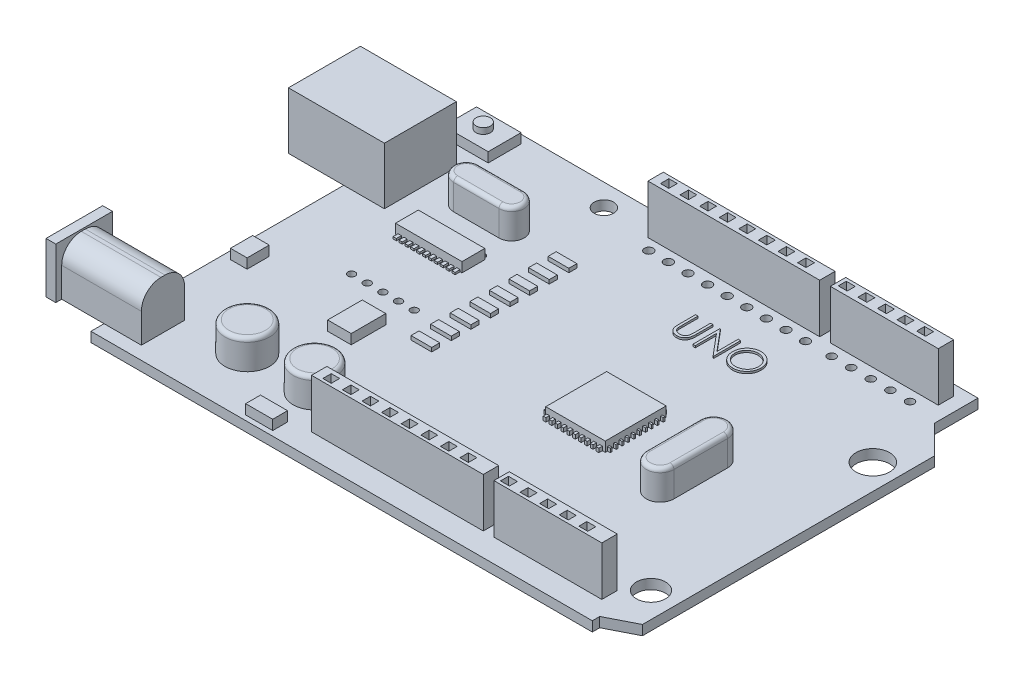
from build123d import *

# Parameters (mm, degrees)
BOSS_EXTRUDE1_DEPTH  = 1.27
SKETCH3_W            = 12.439804233
SKETCH3_H            = 9.329853175
BOSS_EXTRUDE2_DEPTH  = 7.366
SKETCH4_W            = 7.322225457
SKETCH4_H            = 5.447021376
CUT_EXTRUDE1_DEPTH   = 7.366
SKETCH5_W            = 5.784834909
SKETCH5_H            = 4.274350239
BOSS_EXTRUDE3_DEPTH  = 1.27
SKETCH6_R            = 0.927751565
BOSS_EXTRUDE4_DEPTH  = 0.762
SKETCH7_W            = 11.59930364
SKETCH7_H            = 5.603053453
BOSS_EXTRUDE5_DEPTH  = 6.35
FILLET1_R            = 2.54
SKETCH8_W            = 7.353569952
SKETCH8_H            = 6.576337341
BOSS_EXTRUDE6_DEPTH  = 1.27
SKETCH9_R            = 1.784291515
CUT_EXTRUDE2_DEPTH   = 8.89
SKETCH10_W           = 3.393226432
SKETCH10_H           = 2.053794946
BOSS_EXTRUDE7_DEPTH  = 6.35
SKETCH11_R           = 2.891497506
SKETCH11_R_2         = 2.784780473
BOSS_EXTRUDE8_DEPTH  = 3.81
FILLET2_R            = 0.508
FILLET3_R            = 0.508
SKETCH12_W           = 22.265357201
SKETCH12_H           = 1.994930287
SKETCH12_W_2         = 13.992855705
BOSS_EXTRUDE9_DEPTH  = 6.35
SKETCH13_W           = 1.092691039
SKETCH13_H           = 1.092691039
CUT_EXTRUDE3_DEPTH   = 3.81
SKETCH14_W           = 1.159162775
SKETCH14_H           = 1.037145641
CUT_EXTRUDE4_DEPTH   = 3.81
SKETCH15_W           = 7.718255282
SKETCH15_H           = 7.897749591
SKETCH15_W_2         = 8.615726825
SKETCH15_H_2         = 2.961656096
SKETCH15_W_3         = 3.051403251
SKETCH15_H_3         = 4.487357722
SKETCH15_W_4         = 2.153931706
SKETCH15_H_4         = 2.871908942
SKETCH15_W_5         = 3.504585901
SKETCH15_H_5         = 1.927522246
BOSS_EXTRUDE10_DEPTH = 1.27
SKETCH16_R           = 1.256460162
SKETCH16_R_2         = 2.179521727
SKETCH16_R_3         = 1.893030276
SKETCH16_R_4         = 0.477788407
CUT_EXTRUDE5_DEPTH   = 3.81
SKETCH17_W           = 2.681644975
SKETCH17_H           = 1.042861934
BOSS_EXTRUDE11_DEPTH = 0.508
SKETCH20_R           = 0.567610843
CUT_EXTRUDE6_DEPTH   = 23.368
SKETCH21_R           = 0.528248536
CUT_EXTRUDE7_DEPTH   = 13.208
SKETCH22_W           = 0.352103618
SKETCH22_H           = 0.914597611
BOSS_EXTRUDE12_DEPTH = 0.508
SKETCH24_W           = 0.515246595
SKETCH24_H           = 0.230378191
SKETCH24_W_2         = 0.272737657
SKETCH24_H_2         = 0.764205128
BOSS_EXTRUDE13_DEPTH = 0.508
BOSS_EXTRUDE14_DEPTH = 0.254
SKETCH25_W           = 0.425674813
SKETCH25_H           = 4.043342787
BOSS_EXTRUDE15_DEPTH = 0.254


with BuildPart() as part:
    # Sketch2 → Boss-Extrude1 (new body)
    with BuildSketch(Plane(origin=(0, 0, 0), x_dir=(1, 0, 0), z_dir=(0, 1, 0))):
        Polygon((-29.280660377, 14.027122642), (35.719339623, 14.027122642), (35.719339623, 8.393751804), (39.388318456, 4.724772971), (39.388318456, -33.137759083), (35.719339623, -35.010532784), (35.719339623, -35.972877358), (-29.280660377, -35.972877358), align=None)
    extrude(amount=BOSS_EXTRUDE1_DEPTH)

    # Sketch3 → Boss-Extrude2 (add)
    with BuildSketch(Plane(origin=(0, 1.27, 0), x_dir=(1, 0, 0), z_dir=(0, 1, 0))):
        with Locations((-30.228029518, 1.466926875)):
            Rectangle(SKETCH3_W, SKETCH3_H)
    extrude(amount=BOSS_EXTRUDE2_DEPTH)

    # Sketch4 → Cut-Extrude1 (cut)
    with BuildSketch(Plane.ZY.offset(36.447931634)):
        with Locations((-1.74420655, 5.247347114)):
            Rectangle(SKETCH4_W, SKETCH4_H)
    extrude(amount=-CUT_EXTRUDE1_DEPTH, mode=Mode.SUBTRACT)

    # Sketch5 → Boss-Extrude3 (add)
    with BuildSketch(Plane(origin=(0, 1.27, 0), x_dir=(1, 0, 0), z_dir=(0, 1, 0))):
        with Locations((-25.318252468, 10.807240534)):
            Rectangle(SKETCH5_W, SKETCH5_H)
    extrude(amount=BOSS_EXTRUDE3_DEPTH)

    # Sketch6 → Boss-Extrude4 (add)
    with BuildSketch(Plane(origin=(0, 2.54, 0), x_dir=(1, 0, 0), z_dir=(0, 1, 0))):
        with Locations((-25.328780415, 10.938907683)):
            Circle(SKETCH6_R)
    extrude(amount=BOSS_EXTRUDE4_DEPTH)

    # Sketch7 → Boss-Extrude5 (add)
    with BuildSketch(Plane(origin=(0, 1.27, 0), x_dir=(1, 0, 0), z_dir=(0, 1, 0))):
        with Locations((-30.241537665, -31.469115733)):
            Rectangle(SKETCH7_W, SKETCH7_H)
    extrude(amount=BOSS_EXTRUDE5_DEPTH)

    # Fillet1
    fillet1_edges = [part.edges().sort_by_distance(p)[0] for p in [
        (-30.241537665, 7.62, 28.667589006),
        (-30.241537665, 7.62, 34.270642459),
    ]]
    fillet(fillet1_edges, radius=FILLET1_R)

    # Sketch8 → Boss-Extrude6 (add)
    with BuildSketch(Plane.ZY.offset(36.041189485)):
        with Locations((31.359750649, 4.558168671)):
            Rectangle(SKETCH8_W, SKETCH8_H)
    extrude(amount=-BOSS_EXTRUDE6_DEPTH)

    # Sketch9 → Cut-Extrude2 (cut)
    with BuildSketch(Plane.ZY.offset(36.041189485)):
        with Locations((31.327658321, 4.299523558)):
            Circle(SKETCH9_R)
    extrude(amount=-CUT_EXTRUDE2_DEPTH, mode=Mode.SUBTRACT)

    # Sketch10 → Boss-Extrude7 (add)
    with BuildSketch(Plane.ZY.offset(29.081931634)):
        with Locations((-1.804087209, 5.063026243)):
            Rectangle(SKETCH10_W, SKETCH10_H)
    extrude(amount=BOSS_EXTRUDE7_DEPTH)

    # Sketch11 → Boss-Extrude8 (add)
    with BuildSketch(Plane(origin=(0, 1.27, 0), x_dir=(1, 0, 0), z_dir=(0, 1, 0))):
        with Locations((-16.643548114, -28.341824032)):
            Circle(SKETCH11_R)
        with Locations((-7.913597637, -28.341824032)):
            Circle(SKETCH11_R_2)
        with BuildLine():
            Line((-19.172786102, 4.211916531), (-13.298426903, 4.211916531))
            ThreePointArc((-13.298426903, 4.211916531), (-11.666660459, 2.580150087), (-13.298426903, 0.948383643))
            Line((-13.298426903, 0.948383643), (-19.172786102, 0.948383643))
            ThreePointArc((-19.172786102, 0.948383643), (-20.804552547, 2.580150087), (-19.172786102, 4.211916531))
        make_face()
        with BuildLine():
            Line((23.742671381, -17.001047244), (23.742671381, -10.066039856))
            ThreePointArc((23.742671381, -10.066039856), (25.53761447, -8.271096767), (27.332557558, -10.066039856))
            Line((27.332557558, -10.066039856), (27.332557558, -17.001047244))
            ThreePointArc((27.332557558, -17.001047244), (25.53761447, -18.795990333), (23.742671381, -17.001047244))
        make_face()
    extrude(amount=BOSS_EXTRUDE8_DEPTH)

    # Fillet2
    fillet2_edges = [part.edges().sort_by_distance(p)[0] for p in [
        (-19.53504562, 5.08, 28.341824032),
    ]]
    fillet(fillet2_edges, radius=FILLET2_R)

    # Fillet3
    fillet3_edges = [part.edges().sort_by_distance(p)[0] for p in [
        (-10.69837811, 5.08, 28.341824032),
        (-20.804552547, 5.08, -2.580150087),
        (-16.235606503, 5.08, -0.948383643),
        (-11.666660459, 5.08, -2.580150087),
        (-16.235606503, 5.08, -4.211916531),
        (25.53761447, 5.08, 18.795990333),
        (27.332557558, 5.08, 13.53354355),
        (25.53761447, 5.08, 8.271096767),
        (23.742671381, 5.08, 13.53354355),
    ]]
    fillet(fillet3_edges, radius=FILLET3_R)

    # Sketch12 → Boss-Extrude9 (add)
    with BuildSketch(Plane(origin=(0, 1.27, 0), x_dir=(1, 0, 0), z_dir=(0, 1, 0))):
        with Locations((7.441922192, 11.648436516)):
            Rectangle(SKETCH12_W, SKETCH12_H)
        with Locations((26.947539044, 11.648436516)):
            Rectangle(SKETCH12_W_2, SKETCH12_H)
    boss_extrude9 = extrude(amount=BOSS_EXTRUDE9_DEPTH)

    # Sketch13 → Cut-Extrude3 (cut)
    with BuildSketch(Plane(origin=(0, 7.62, 0), x_dir=(1, 0, 0), z_dir=(0, 1, 0))):
        with Locations((0.486116413, 11.725008127)):
            Rectangle(SKETCH13_W, SKETCH13_H)
        with Locations((-2.053883588, 11.725008127)):
            Rectangle(SKETCH13_W, SKETCH13_H)
        with Locations((3.026116413, 11.725008127)):
            Rectangle(SKETCH13_W, SKETCH13_H)
        with Locations((5.566116413, 11.725008127)):
            Rectangle(SKETCH13_W, SKETCH13_H)
        with Locations((8.106116413, 11.725008127)):
            Rectangle(SKETCH13_W, SKETCH13_H)
        with Locations((10.646116412, 11.725008127)):
            Rectangle(SKETCH13_W, SKETCH13_H)
        with Locations((13.186116413, 11.725008127)):
            Rectangle(SKETCH13_W, SKETCH13_H)
        with Locations((15.726116413, 11.725008127)):
            Rectangle(SKETCH13_W, SKETCH13_H)
    cut_extrude3 = extrude(amount=-CUT_EXTRUDE3_DEPTH, mode=Mode.SUBTRACT)

    # Sketch14 → Cut-Extrude4 (cut)
    with BuildSketch(Plane(origin=(0, 7.62, 0), x_dir=(1, 0, 0), z_dir=(0, 1, 0))):
        with Locations((20.994355557, 11.737127992)):
            Rectangle(SKETCH14_W, SKETCH14_H)
        with Locations((23.534355557, 11.737127992)):
            Rectangle(SKETCH14_W, SKETCH14_H)
        with Locations((26.074355557, 11.737127992)):
            Rectangle(SKETCH14_W, SKETCH14_H)
        with Locations((28.614355557, 11.737127992)):
            Rectangle(SKETCH14_W, SKETCH14_H)
        with Locations((31.154355557, 11.737127992)):
            Rectangle(SKETCH14_W, SKETCH14_H)
    cut_extrude4 = extrude(amount=-CUT_EXTRUDE4_DEPTH, mode=Mode.SUBTRACT)

    # Mirror1: Boss-Extrude9, Cut-Extrude3 across Plane1
    add(boss_extrude9.mirror(Plane.XY.offset(10.16)))
    add(cut_extrude3.mirror(Plane.XY.offset(10.16)), mode=Mode.SUBTRACT)

    # Mirror2: Cut-Extrude4 across plane
    add(cut_extrude4.mirror(Plane.XY.offset(10.16)), mode=Mode.SUBTRACT)

    # Sketch15 → Boss-Extrude10 (add)
    with BuildSketch(Plane(origin=(0, 1.27, 0), x_dir=(1, 0, 0), z_dir=(0, 1, 0))):
        with Locations((13.795002464, -12.281332963)):
            Rectangle(SKETCH15_W, SKETCH15_H)
        with Locations((-16.090799963, -3.889974023)):
            Rectangle(SKETCH15_W_2, SKETCH15_H_2)
        with Locations((-12.411166631, -18.384139464)):
            Rectangle(SKETCH15_W_3, SKETCH15_H_3)
        with Locations((-27.206493385, -17.445373353)):
            Rectangle(SKETCH15_W_4, SKETCH15_H_4)
        with Locations((-8.102029847, -34.375255486)):
            Rectangle(SKETCH15_W_5, SKETCH15_H_5)
    extrude(amount=BOSS_EXTRUDE10_DEPTH)

    # Sketch16 → Cut-Extrude5 (cut)
    with BuildSketch(Plane(origin=(0, 1.27, 0), x_dir=(1, 0, 0), z_dir=(0, 1, 0))):
        with Locations((-9.905759976, 11.14826514)):
            Circle(SKETCH16_R)
        with Locations((36.110119022, 0)):
            Circle(SKETCH16_R_2)
        with Locations((36.110119022, -28.759422527)):
            Circle(SKETCH16_R_3)
        with Locations((-18.815590525, -12.652172907)):
            Circle(SKETCH16_R_4)
        with Locations((-16.783590525, -12.652172907)):
            Circle(SKETCH16_R_4)
        with Locations((-14.751590525, -12.652172907)):
            Circle(SKETCH16_R_4)
        with Locations((-12.719590525, -12.652172907)):
            Circle(SKETCH16_R_4)
        with Locations((-10.687590525, -12.652172907)):
            Circle(SKETCH16_R_4)
    extrude(amount=-CUT_EXTRUDE5_DEPTH, mode=Mode.SUBTRACT)

    # Sketch17 → Boss-Extrude11 (add)
    with BuildSketch(Plane(origin=(0, 1.27, 0), x_dir=(1, 0, 0), z_dir=(0, 1, 0))):
        with Locations((-6.209480098, -15.688538074)):
            Rectangle(SKETCH17_W, SKETCH17_H)
        with Locations((-6.209480098, -13.148538074)):
            Rectangle(SKETCH17_W, SKETCH17_H)
        with Locations((-6.209480098, -10.608538074)):
            Rectangle(SKETCH17_W, SKETCH17_H)
        with Locations((-6.209480098, -8.068538074)):
            Rectangle(SKETCH17_W, SKETCH17_H)
        with Locations((-6.209480098, -5.528538074)):
            Rectangle(SKETCH17_W, SKETCH17_H)
        with Locations((-6.209480098, -2.988538074)):
            Rectangle(SKETCH17_W, SKETCH17_H)
        with Locations((-6.209480098, -0.448538074)):
            Rectangle(SKETCH17_W, SKETCH17_H)
        with Locations((-6.209480098, 2.091461926)):
            Rectangle(SKETCH17_W, SKETCH17_H)
    extrude(amount=BOSS_EXTRUDE11_DEPTH)

    # Sketch20 → Cut-Extrude6 (cut)
    with BuildSketch(Plane(origin=(0, 1.27, 0), x_dir=(1, 0, 0), z_dir=(0, 1, 0))):
        with Locations((-2.165660729, -29.556046432)):
            Circle(SKETCH20_R)
        with Locations((0.374339271, -29.556046432)):
            Circle(SKETCH20_R)
        with Locations((2.914339271, -29.556046432)):
            Circle(SKETCH20_R)
        with Locations((5.454339271, -29.556046432)):
            Circle(SKETCH20_R)
        with Locations((7.994339271, -29.556046432)):
            Circle(SKETCH20_R)
        with Locations((10.534339271, -29.556046432)):
            Circle(SKETCH20_R)
        with Locations((13.074339271, -29.556046432)):
            Circle(SKETCH20_R)
        with Locations((15.614339271, -29.556046432)):
            Circle(SKETCH20_R)
        with Locations((18.154339271, -29.556046432)):
            Circle(SKETCH20_R)
    cut_extrude6 = extrude(amount=-CUT_EXTRUDE6_DEPTH, mode=Mode.SUBTRACT)

    # Sketch21 → Cut-Extrude7 (cut)
    with BuildSketch(Plane(origin=(0, 1.27, 0), x_dir=(1, 0, 0), z_dir=(0, 1, 0))):
        with Locations((21.543232299, -29.549508263)):
            Circle(SKETCH21_R)
        with Locations((24.083232299, -29.549508263)):
            Circle(SKETCH21_R)
        with Locations((26.623232299, -29.549508263)):
            Circle(SKETCH21_R)
        with Locations((29.163232299, -29.549508263)):
            Circle(SKETCH21_R)
        with Locations((31.703232299, -29.549508263)):
            Circle(SKETCH21_R)
    cut_extrude7 = extrude(amount=-CUT_EXTRUDE7_DEPTH, mode=Mode.SUBTRACT)

    # Mirror3: Cut-Extrude6, Cut-Extrude7 across plane
    add(cut_extrude6.mirror(Plane.XY.offset(10.16)), mode=Mode.SUBTRACT)
    add(cut_extrude7.mirror(Plane.XY.offset(10.16)), mode=Mode.SUBTRACT)

    # Sketch22 → Boss-Extrude12 (add)
    with BuildSketch(Plane(origin=(0, 1.27, 0), x_dir=(1, 0, 0), z_dir=(0, 1, 0))):
        with Locations((10.247981412, -16.230207758)):
            Rectangle(SKETCH22_W, SKETCH22_H)
        with Locations((11.009981412, -16.230207758)):
            Rectangle(SKETCH22_W, SKETCH22_H)
        with Locations((11.771981412, -16.230207758)):
            Rectangle(SKETCH22_W, SKETCH22_H)
        with Locations((12.533981412, -16.230207758)):
            Rectangle(SKETCH22_W, SKETCH22_H)
        with Locations((13.295981412, -16.230207758)):
            Rectangle(SKETCH22_W, SKETCH22_H)
        with Locations((14.057981412, -16.230207758)):
            Rectangle(SKETCH22_W, SKETCH22_H)
        with Locations((14.819981412, -16.230207758)):
            Rectangle(SKETCH22_W, SKETCH22_H)
        with Locations((15.581981412, -16.230207758)):
            Rectangle(SKETCH22_W, SKETCH22_H)
        with Locations((16.343981412, -16.230207758)):
            Rectangle(SKETCH22_W, SKETCH22_H)
        with Locations((17.105981412, -16.230207758)):
            Rectangle(SKETCH22_W, SKETCH22_H)
    extrude(amount=BOSS_EXTRUDE12_DEPTH)

    # Sketch24 → Boss-Extrude13 (add)
    with BuildSketch(Plane(origin=(0, 1.27, 0), x_dir=(1, 0, 0), z_dir=(0, 1, 0))):
        with Locations((9.678251526, -15.831618677)):
            Rectangle(SKETCH24_W, SKETCH24_H)
        with Locations((9.678251526, -15.069618677)):
            Rectangle(SKETCH24_W, SKETCH24_H)
        with Locations((9.678251526, -14.307618677)):
            Rectangle(SKETCH24_W, SKETCH24_H)
        with Locations((9.678251526, -13.545618677)):
            Rectangle(SKETCH24_W, SKETCH24_H)
        with Locations((9.678251526, -12.783618677)):
            Rectangle(SKETCH24_W, SKETCH24_H)
        with Locations((9.678251526, -12.021618677)):
            Rectangle(SKETCH24_W, SKETCH24_H)
        with Locations((9.678251526, -11.259618677)):
            Rectangle(SKETCH24_W, SKETCH24_H)
        with Locations((9.678251526, -10.497618677)):
            Rectangle(SKETCH24_W, SKETCH24_H)
        with Locations((9.678251526, -9.735618676)):
            Rectangle(SKETCH24_W, SKETCH24_H)
        with Locations((9.678251526, -8.973618677)):
            Rectangle(SKETCH24_W, SKETCH24_H)
        with Locations((17.768713592, -8.973618677)):
            Rectangle(SKETCH24_W, SKETCH24_H)
        with Locations((17.768713592, -9.735618676)):
            Rectangle(SKETCH24_W, SKETCH24_H)
        with Locations((17.768713592, -10.497618677)):
            Rectangle(SKETCH24_W, SKETCH24_H)
        with Locations((17.768713592, -11.259618677)):
            Rectangle(SKETCH24_W, SKETCH24_H)
        with Locations((17.768713592, -12.021618677)):
            Rectangle(SKETCH24_W, SKETCH24_H)
        with Locations((17.768713592, -12.783618677)):
            Rectangle(SKETCH24_W, SKETCH24_H)
        with Locations((17.768713592, -13.545618677)):
            Rectangle(SKETCH24_W, SKETCH24_H)
        with Locations((17.768713592, -14.307618677)):
            Rectangle(SKETCH24_W, SKETCH24_H)
        with Locations((17.768713592, -15.069618677)):
            Rectangle(SKETCH24_W, SKETCH24_H)
        with Locations((17.768713592, -15.831618677)):
            Rectangle(SKETCH24_W, SKETCH24_H)
        with Locations((10.351210913, -8.332458167)):
            Rectangle(SKETCH24_W_2, SKETCH24_H_2)
        with Locations((11.113210913, -8.332458167)):
            Rectangle(SKETCH24_W_2, SKETCH24_H_2)
        with Locations((11.875210913, -8.332458167)):
            Rectangle(SKETCH24_W_2, SKETCH24_H_2)
        with Locations((12.637210913, -8.332458167)):
            Rectangle(SKETCH24_W_2, SKETCH24_H_2)
        with Locations((13.399210913, -8.332458167)):
            Rectangle(SKETCH24_W_2, SKETCH24_H_2)
        with Locations((14.161210913, -8.332458167)):
            Rectangle(SKETCH24_W_2, SKETCH24_H_2)
        with Locations((14.923210913, -8.332458167)):
            Rectangle(SKETCH24_W_2, SKETCH24_H_2)
        with Locations((15.685210913, -8.332458167)):
            Rectangle(SKETCH24_W_2, SKETCH24_H_2)
        with Locations((16.447210913, -8.332458167)):
            Rectangle(SKETCH24_W_2, SKETCH24_H_2)
        with Locations((17.209210913, -8.332458167)):
            Rectangle(SKETCH24_W_2, SKETCH24_H_2)
    extrude(amount=BOSS_EXTRUDE13_DEPTH)

    # Sketch18 → Boss-Extrude14 (add)
    with BuildSketch(Plane(origin=(0, 1.27, 0), x_dir=(1, 0, 0), z_dir=(0, 1, 0))):
        with BuildLine():
            Line((8.302436642, 4.838207115), (8.616539206, 4.838207115))
            Line((8.616539206, 4.838207115), (8.616539206, 2.741151827))
            add(Edge.make_bspline(
                [(8.616539206, 2.741151827), (8.616492462, 2.711471091), (8.616403758, 2.65514678), (8.616996271, 2.57497848), (8.61865564, 2.503706021), (8.619701799, 2.441054673), (8.622029133, 2.387311925), (8.62392718, 2.342186615), (8.626367737, 2.305892412), (8.629300854, 2.284711486), (8.630561642, 2.275606955)],
                knots=[0, 0, 0, 0, 8.9042e-05, 0.000168973, 0.000240502, 0.000302917, 0.000356945, 0.000401866, 0.000438432, 0.000465999, 0.000465999, 0.000465999, 0.000465999], degree=3))
            add(Edge.make_bspline(
                [(8.630561642, 2.275606955), (8.635739101, 2.242760192), (8.645802287, 2.178917463), (8.671448665, 2.088009181), (8.707266166, 2.006077722), (8.749709209, 1.930566431), (8.80564182, 1.863577071), (8.872645355, 1.801865418), (8.953823124, 1.747893614), (9.04408373, 1.698542802), (9.141368967, 1.65887772), (9.240780234, 1.628884355), (9.340823213, 1.610605455), (9.407799378, 1.608488917), (9.441058437, 1.607437884)],
                knots=[0, 0, 0, 0, 9.971e-05, 0.000193801, 0.000282365, 0.000367504, 0.000452699, 0.000543015, 0.000639862, 0.000744331, 0.000851226, 0.000954377, 0.001055468, 0.001155185, 0.001155185, 0.001155185, 0.001155185], degree=3))
            add(Edge.make_bspline(
                [(9.441058437, 1.607437884), (9.469612177, 1.608511735), (9.526554739, 1.610653233), (9.61116117, 1.623914664), (9.693561279, 1.64781523), (9.774161959, 1.678654988), (9.849712943, 1.719402579), (9.920256385, 1.766473419), (9.983220319, 1.821684295), (10.040678317, 1.882784639), (10.090713253, 1.951724439), (10.134084395, 2.027002577), (10.169610324, 2.109751924), (10.187153849, 2.167906346), (10.19616661, 2.197782436)],
                knots=[0, 0, 0, 0, 8.5678e-05, 0.00017086, 0.000256092, 0.000342674, 0.000429242, 0.000513055, 0.000596556, 0.000679898, 0.000764179, 0.00085149, 0.000940054, 0.001033621, 0.001033621, 0.001033621, 0.001033621], degree=3))
            add(Edge.make_bspline(
                [(10.19616661, 2.197782436), (10.199166735, 2.21013101), (10.205852224, 2.23764861), (10.212099269, 2.284169901), (10.218605794, 2.339059265), (10.223120364, 2.402711078), (10.227521584, 2.47491205), (10.230154657, 2.556038308), (10.23137169, 2.645795268), (10.231734371, 2.70843243), (10.231923822, 2.741151827)],
                knots=[0, 0, 0, 0, 3.81e-05, 8.4902e-05, 0.000140649, 0.000203941, 0.000276279, 0.000357657, 0.000447412, 0.000545571, 0.000545571, 0.000545571, 0.000545571], degree=3))
            Line((10.231923822, 2.741151827), (10.231923822, 4.838207115))
            Line((10.231923822, 4.838207115), (10.546026386, 4.838207115))
            Line((10.546026386, 4.838207115), (10.546026386, 2.724324904))
            add(Edge.make_bspline(
                [(10.546026386, 2.724324904), (10.545772265, 2.686226525), (10.545276334, 2.611875222), (10.540975758, 2.502923863), (10.534118758, 2.399570882), (10.52443067, 2.301802385), (10.511593667, 2.209968226), (10.497318446, 2.123263458), (10.479138913, 2.042310465), (10.457905512, 1.966478047), (10.433631964, 1.894292534), (10.402190815, 1.825783919), (10.366766315, 1.75886952), (10.324751663, 1.694561411), (10.27754028, 1.632574858), (10.224088599, 1.573285783), (10.166164438, 1.515746736), (10.102804879, 1.46143367), (10.035054353, 1.411624993), (9.963114396, 1.367827222), (9.887537626, 1.330803605), (9.8085205, 1.30032768), (9.726029297, 1.277413081), (9.640061937, 1.260337925), (9.550422744, 1.250635628), (9.489458088, 1.249193698), (9.458586482, 1.248463526)],
                knots=[0, 0, 0, 0, 0.000114291, 0.000223047, 0.000327049, 0.000424998, 0.000517708, 0.000605194, 0.000688542, 0.000766455, 0.0008414, 0.000916717, 0.000992315, 0.001068354, 0.001146882, 0.001225836, 0.001307639, 0.001391671, 0.001475952, 0.001559641, 0.001643989, 0.001728103, 0.001813335, 0.001900511, 0.00199079, 0.002083404, 0.002083404, 0.002083404, 0.002083404], degree=3))
            add(Edge.make_bspline(
                [(9.458586482, 1.248463526), (9.424917379, 1.249248291), (9.35885872, 1.250787997), (9.261520653, 1.259610748), (9.168206457, 1.276229142), (9.07793058, 1.297389086), (8.991922083, 1.326572823), (8.909028638, 1.360670948), (8.830669957, 1.402548208), (8.755574829, 1.449141601), (8.685750072, 1.501566239), (8.621652669, 1.558706413), (8.563176799, 1.619646791), (8.511308102, 1.685047156), (8.465187218, 1.754398863), (8.425457004, 1.827898103), (8.39134376, 1.905516419), (8.373737193, 1.95946962), (8.364836482, 1.986744776)],
                knots=[0, 0, 0, 0, 0.000101022, 0.000198206, 0.000292839, 0.000385177, 0.00047608, 0.000565014, 0.000653769, 0.000742283, 0.000829923, 0.000915339, 0.000999643, 0.001082971, 0.00116542, 0.001249186, 0.001333332, 0.001419362, 0.001419362, 0.001419362, 0.001419362], degree=3))
            add(Edge.make_bspline(
                [(8.364836482, 1.986744776), (8.359659324, 2.00537735), (8.348429952, 2.045791819), (8.336404655, 2.112678307), (8.326295573, 2.189693225), (8.316790015, 2.276841843), (8.311181057, 2.37419171), (8.306263618, 2.481700626), (8.302401999, 2.599498588), (8.302424772, 2.681553103), (8.302436642, 2.724324904)],
                knots=[0, 0, 0, 0, 5.799e-05, 0.000125782, 0.000203619, 0.000291034, 0.000388694, 0.000496078, 0.000613919, 0.000742226, 0.000742226, 0.000742226, 0.000742226], degree=3))
            Line((8.302436642, 2.724324904), (8.302436642, 4.838207115))
        make_face()
        Polygon((11.443462283, 1.338207115), (11.443462283, 4.838207115), (11.509367732, 4.838207115), (13.821667411, 2.083499583), (13.821667411, 4.838207115), (14.135769976, 4.838207115), (14.135769976, 1.338207115), (14.064255552, 1.338207115), (11.757564847, 4.086604551), (11.757564847, 1.338207115), align=None)
        with BuildLine():
            add(Edge.make_bspline(
                [(16.671026386, 4.927950705), (16.735834492, 4.926309226), (16.863122959, 4.923085225), (17.050197856, 4.898406121), (17.228792952, 4.855710731), (17.40036309, 4.798847749), (17.562856067, 4.722993363), (17.71749496, 4.631308215), (17.863911833, 4.522831756), (18.000133215, 4.398402529), (18.124790165, 4.263019075), (18.234616051, 4.118541165), (18.326658345, 3.965842363), (18.402244132, 3.805381532), (18.461542742, 3.637521564), (18.502461786, 3.461367562), (18.528599936, 3.278060872), (18.531655713, 3.153034007), (18.533205873, 3.089609359)],
                knots=[0, 0, 0, 0, 0.000194393, 0.000381804, 0.00056479, 0.000744601, 0.000923091, 0.001101652, 0.001283106, 0.001468738, 0.001654324, 0.001834514, 0.002012231, 0.002188181, 0.002365797, 0.002545211, 0.002729936, 0.002920126, 0.002920126, 0.002920126, 0.002920126], degree=3))
            add(Edge.make_bspline(
                [(18.533205873, 3.089609359), (18.53165594, 3.026651912), (18.528600844, 2.902555492), (18.502432066, 2.720412048), (18.461391066, 2.545321351), (18.4027948, 2.377575699), (18.327569322, 2.216998135), (18.234914151, 2.064011181), (18.12577294, 1.918564683), (18.001566089, 1.782252017), (17.866165047, 1.657254547), (17.72093478, 1.548335671), (17.56914146, 1.454611546), (17.408831752, 1.379827872), (17.242131715, 1.320055952), (17.067549392, 1.279303322), (16.885902838, 1.253016279), (16.762031834, 1.249997763), (16.699071258, 1.248463526)],
                knots=[0, 0, 0, 0, 0.000188789, 0.000372126, 0.000550857, 0.00072758, 0.000904164, 0.001081881, 0.001263191, 0.001448823, 0.00163441, 0.001815159, 0.001992641, 0.002168591, 0.002344885, 0.002522934, 0.002705576, 0.002894365, 0.002894365, 0.002894365, 0.002894365], degree=3))
            add(Edge.make_bspline(
                [(16.699071258, 1.248463526), (16.635646939, 1.250012912), (16.510620723, 1.253067166), (16.327083687, 1.279248571), (16.150805943, 1.320189875), (15.982291592, 1.378699311), (15.821446663, 1.454316542), (15.66795658, 1.546520921), (15.522437433, 1.655928062), (15.386095686, 1.780094637), (15.261346488, 1.915266189), (15.152587112, 2.060100444), (15.060361999, 2.2117559), (14.984998667, 2.370653425), (14.925334207, 2.536024867), (14.884629389, 2.708973345), (14.858293437, 2.888512851), (14.85525859, 3.010755749), (14.853718693, 3.072782436)],
                knots=[0, 0, 0, 0, 0.00019019, 0.000374915, 0.000555011, 0.000732396, 0.00090898, 0.001087298, 0.001268608, 0.00145424, 0.001639827, 0.001819595, 0.001996712, 0.002171394, 0.002346367, 0.002523053, 0.002703612, 0.002889599, 0.002889599, 0.002889599, 0.002889599], degree=3))
            add(Edge.make_bspline(
                [(14.853718693, 3.072782436), (14.854253329, 3.114415105), (14.855315855, 3.197155228), (14.868107548, 3.320021829), (14.886669249, 3.440912486), (14.913271162, 3.559483434), (14.948062829, 3.675444419), (14.989114856, 3.789595182), (15.039254701, 3.900778906), (15.095935349, 4.009522297), (15.159197157, 4.114130203), (15.229072907, 4.213009786), (15.303108275, 4.306990783), (15.384271669, 4.393637787), (15.469888114, 4.475471443), (15.561346492, 4.55123416), (15.658088737, 4.621609111), (15.760531116, 4.685029452), (15.866149391, 4.742388587), (15.975026169, 4.791610438), (16.085682741, 4.833856499), (16.198637388, 4.868097325), (16.313590161, 4.895129361), (16.430791945, 4.913536714), (16.550149371, 4.926361032), (16.63056069, 4.927418534), (16.671026386, 4.927950705)],
                knots=[0, 0, 0, 0, 0.000124849, 0.000248123, 0.000370193, 0.00049164, 0.000612319, 0.000733199, 0.000855287, 0.000977905, 0.001100913, 0.001221706, 0.001340948, 0.001459521, 0.001577551, 0.001696047, 0.001815534, 0.001936153, 0.002057243, 0.002175846, 0.002294342, 0.002412335, 0.002529682, 0.00264829, 0.002768075, 0.00288942, 0.00288942, 0.00288942, 0.00288942], degree=3))
        make_face()
        with BuildLine():
            add(Edge.make_bspline(
                [(16.686451065, 4.568976346), (16.653236432, 4.568571456), (16.587124699, 4.567765546), (16.488840163, 4.55714983), (16.391848229, 4.542019941), (16.296128867, 4.520438421), (16.202082577, 4.491034368), (16.108832736, 4.45719346), (16.017229682, 4.415972369), (15.927575824, 4.369399665), (15.840660749, 4.317850744), (15.758648048, 4.260878977), (15.681325404, 4.199820423), (15.608882137, 4.134532585), (15.541530965, 4.064682984), (15.477946263, 3.991330547), (15.420676682, 3.912378656), (15.368191105, 3.82996825), (15.321223265, 3.744206668), (15.27945791, 3.655996806), (15.245293901, 3.564619119), (15.217431525, 3.471064962), (15.194331714, 3.375482502), (15.17969779, 3.277146653), (15.16896543, 3.176551541), (15.168205585, 3.108569687), (15.167821258, 3.074184679)],
                knots=[0, 0, 0, 0, 9.9599e-05, 0.000198245, 0.000296222, 0.00039402, 0.00049227, 0.000591646, 0.000691452, 0.000793368, 0.000894612, 0.000994383, 0.001092713, 0.00119001, 0.001286696, 0.001383657, 0.001480979, 0.001579008, 0.001676595, 0.001774142, 0.001871547, 0.001968922, 0.002066879, 0.00216624, 0.00226698, 0.002370083, 0.002370083, 0.002370083, 0.002370083], degree=3))
            add(Edge.make_bspline(
                [(15.167821258, 3.074184679), (15.16909612, 3.023622459), (15.171604167, 2.924150928), (15.193561738, 2.778382784), (15.227383712, 2.638294498), (15.277241078, 2.504652589), (15.339591693, 2.376308306), (15.416618583, 2.254400201), (15.507877669, 2.138895327), (15.611541196, 2.030600058), (15.724863902, 1.931754254), (15.845196632, 1.844990845), (15.97125024, 1.771580595), (16.103353442, 1.711775523), (16.240800981, 1.664385785), (16.384478532, 1.631907154), (16.533428992, 1.610531699), (16.634959647, 1.608478943), (16.686451065, 1.607437884)],
                knots=[0, 0, 0, 0, 0.000151605, 0.000298253, 0.000441263, 0.000583229, 0.000725274, 0.000868635, 0.001014928, 0.001166177, 0.001317744, 0.00146543, 0.001610576, 0.001754594, 0.001899821, 0.002045914, 0.002195936, 0.002350312, 0.002350312, 0.002350312, 0.002350312], degree=3))
            add(Edge.make_bspline(
                [(16.686451065, 1.607437884), (16.721060567, 1.607913389), (16.789701603, 1.608856457), (16.891797126, 1.618355134), (16.992053337, 1.633587003), (17.090329617, 1.655517659), (17.186514429, 1.682964865), (17.281009232, 1.715572593), (17.372807522, 1.756253797), (17.46306736, 1.801201748), (17.549463602, 1.852441906), (17.631939134, 1.907480056), (17.708415114, 1.968448676), (17.780804185, 2.032766489), (17.848431874, 2.101730337), (17.910840858, 2.175250558), (17.96782099, 2.253791216), (18.020286637, 2.336076621), (18.0670899, 2.422072874), (18.107868999, 2.510602552), (18.142465115, 2.601447661), (18.17039362, 2.694739233), (18.192279081, 2.790300082), (18.207359001, 2.88825816), (18.21790744, 2.988417502), (18.218702517, 3.056161358), (18.219103309, 3.090310481)],
                knots=[0, 0, 0, 0, 0.000103804, 0.000205874, 0.000307314, 0.000407849, 0.000507719, 0.000607281, 0.000707445, 0.000808723, 0.000909609, 0.001008589, 0.001105934, 0.001202762, 0.001298946, 0.001395452, 0.001491794, 0.001589823, 0.001688026, 0.001785277, 0.001882027, 0.001979402, 0.0020772, 0.002175869, 0.002276609, 0.002379011, 0.002379011, 0.002379011, 0.002379011], degree=3))
            add(Edge.make_bspline(
                [(18.219103309, 3.090310481), (18.218702196, 3.124225985), (18.217906514, 3.191503635), (18.20736404, 3.290964453), (18.192263149, 3.388217665), (18.170500441, 3.482881468), (18.142450288, 3.574979993), (18.107862957, 3.664426741), (18.067077658, 3.751554936), (18.020269433, 3.836149233), (17.96765361, 3.917323971), (17.910159367, 3.994926383), (17.846794018, 4.067499125), (17.779367994, 4.136833819), (17.706197108, 4.201451708), (17.627612814, 4.261374229), (17.544569136, 4.318047503), (17.456641901, 4.369173065), (17.365897947, 4.416387298), (17.272783989, 4.456838301), (17.17835489, 4.49121042), (17.082850777, 4.520527385), (16.985467799, 4.541935415), (16.88686397, 4.557163465), (16.787175712, 4.567761851), (16.720132492, 4.56857023), (16.686451065, 4.568976346)],
                knots=[0, 0, 0, 0, 0.000101701, 0.000201743, 0.00029972, 0.000396835, 0.000492868, 0.000588308, 0.000684288, 0.000781261, 0.000878109, 0.000974304, 0.001070733, 0.001166917, 0.001264269, 0.001363274, 0.001463228, 0.001565678, 0.001668217, 0.001769947, 0.001869982, 0.001969573, 0.002069423, 0.002168785, 0.002268827, 0.002369827, 0.002369827, 0.002369827, 0.002369827], degree=3))
        make_face(mode=Mode.SUBTRACT)
    extrude(amount=BOSS_EXTRUDE14_DEPTH)

    # Sketch25 → Boss-Extrude15 (add)
    with BuildSketch(Plane(origin=(0, 1.27, 0), x_dir=(1, 0, 0), z_dir=(0, 1, 0))):
        with Locations((-19.092220809, -3.999380955)):
            Rectangle(SKETCH25_W, SKETCH25_H)
        with Locations((-19.854220809, -3.999380955)):
            Rectangle(SKETCH25_W, SKETCH25_H)
        with Locations((-18.330220809, -3.999380955)):
            Rectangle(SKETCH25_W, SKETCH25_H)
        with Locations((-17.568220809, -3.999380955)):
            Rectangle(SKETCH25_W, SKETCH25_H)
        with Locations((-16.806220809, -3.999380955)):
            Rectangle(SKETCH25_W, SKETCH25_H)
        with Locations((-16.044220809, -3.999380955)):
            Rectangle(SKETCH25_W, SKETCH25_H)
        with Locations((-15.282220808, -3.999380955)):
            Rectangle(SKETCH25_W, SKETCH25_H)
        with Locations((-14.520220809, -3.999380955)):
            Rectangle(SKETCH25_W, SKETCH25_H)
        with Locations((-13.758220809, -3.999380955)):
            Rectangle(SKETCH25_W, SKETCH25_H)
        with Locations((-12.996220809, -3.999380955)):
            Rectangle(SKETCH25_W, SKETCH25_H)
        with Locations((-12.234220809, -3.999380955)):
            Rectangle(SKETCH25_W, SKETCH25_H)
    extrude(amount=BOSS_EXTRUDE15_DEPTH)


solid = part.part
